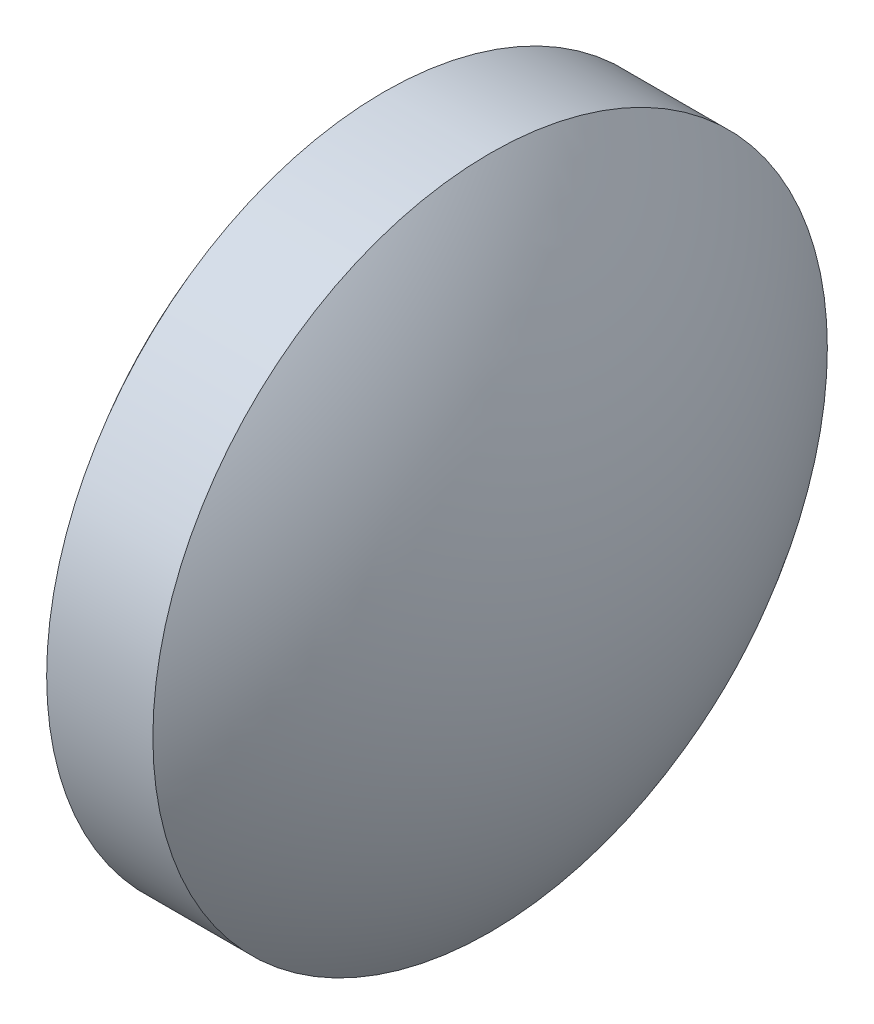
from build123d import *

# Parameters (mm, degrees)
SKETCH_1_ONE_SIDE_W = 2.000068571
SKETCH_1_ONE_SIDE_H = 6.35


with BuildPart() as part:
    # 草图1 one side → 旋转1 (revolve)
    with BuildSketch(Plane.XY):
        with Locations((43.229096888, 27.483056512)):
            Rectangle(SKETCH_1_ONE_SIDE_W, SKETCH_1_ONE_SIDE_H)
        with BuildLine():
            Line((40.09945403, 24.308056512), (42.229062602, 24.308056512))
            Line((42.229062602, 24.308056512), (42.229062602, 30.658056512))
            ThreePointArc((42.229062602, 30.658056512), (40.646039518, 27.65685229), (40.09945403, 24.308056512))
        make_face()
        with BuildLine():
            Line((44.229131173, 24.308056512), (46.358739744, 24.308056512))
            ThreePointArc((46.358739744, 24.308056512), (45.812154257, 27.65685229), (44.229131173, 30.658056512))
            Line((44.229131173, 30.658056512), (44.229131173, 24.308056512))
        make_face()
    revolve(axis=Axis((35.826820107, 24.308056512, 0), (1, 0, 0)))


solid = part.part
